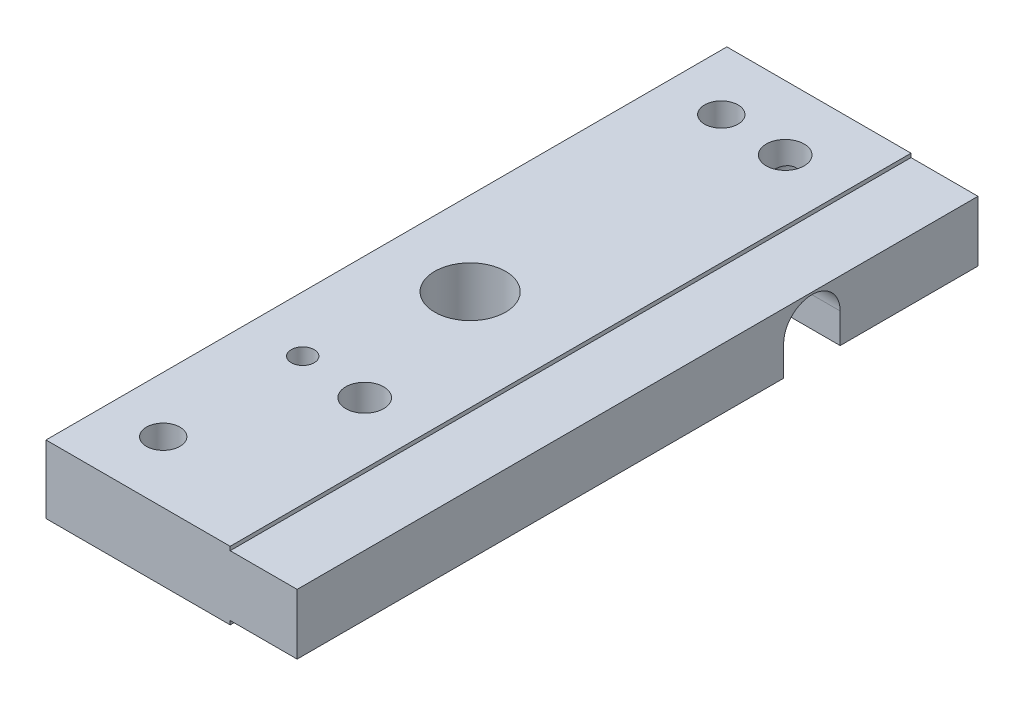
from build123d import *

# Parameters (mm, degrees)
SKETCH1_W                                        = 61
SKETCH1_H                                        = 6.1
BOSS_EXTRUDE1_DEPTH                              = 22.5
SKETCH2_OUTSIDE_W                                = 76.06
SKETCH2_OUTSIDE_H                                = 21.16
SKETCH2_OUTSIDE_W_2                              = 61
SKETCH2_OUTSIDE_H_2                              = 5.41284
CUT_EXTRUDE1_DEPTH                               = 6
CUT_EXTRUDE3_DEPTH                               = 23.5
SKETCH6_R                                        = 3.175
CUT_EXTRUDE4_DEPTH                               = 7.1
SKETCH7_R                                        = 1.5
CUT_EXTRUDE5_DEPTH                               = 7.1
M2_5X0_45_TAPPED_HOLE1_D                         = 2.05
M2_5X0_45_TAPPED_HOLE2_D                         = 2.05
M2_5X0_45_TAPPED_HOLE2_DEPTH                     = 7.3
M2_5X0_45_TAPPED_HOLE2_TIP                       = 0.615882135
CBORE_FOR_M3_PAN_HEAD_MACHINE_SCREW1_D           = 3.4
CBORE_FOR_M3_PAN_HEAD_MACHINE_SCREW1_CBORE_D     = 6.5
CBORE_FOR_M3_PAN_HEAD_MACHINE_SCREW1_CBORE_DEPTH = 2.2


with BuildPart() as part:
    # Sketch1 → Boss-Extrude1 (new body)
    with BuildSketch(Plane(origin=(0, 0, 0), x_dir=(0, 0, -1), z_dir=(1, 0, 0))):
        with Locations((30.5, 0)):
            Rectangle(SKETCH1_W, SKETCH1_H)
    extrude(amount=BOSS_EXTRUDE1_DEPTH)

    # Sketch2 outside → Cut-Extrude1 (cut)
    with BuildSketch(Plane(origin=(22.5, 0, 0), x_dir=(0, 0, -1), z_dir=(1, 0, 0))):
        with Locations((30.5, 0)):
            Rectangle(SKETCH2_OUTSIDE_W, SKETCH2_OUTSIDE_H)
        with Locations((30.5, 0)):
            Rectangle(SKETCH2_OUTSIDE_W_2, SKETCH2_OUTSIDE_H_2, mode=Mode.SUBTRACT)
    extrude(amount=-CUT_EXTRUDE1_DEPTH, mode=Mode.SUBTRACT)

    # Sketch5 → Cut-Extrude3 (cut, through all)
    with BuildSketch(Plane.ZY):
        with BuildLine():
            Line((-43.5866, -0.01898), (-43.5866, -3.05))
            Line((-43.5866, -3.05), (-48.6514, -3.05))
            Line((-48.6514, -3.05), (-48.6514, -0.01898))
            ThreePointArc((-48.6514, -0.01898), (-46.119, 2.51342), (-43.5866, -0.01898))
        make_face()
    extrude(amount=-CUT_EXTRUDE3_DEPTH, mode=Mode.SUBTRACT)

    # Sketch6 → Cut-Extrude4 (cut, through all)
    with BuildSketch(Plane(origin=(0, 3.05, 0), x_dir=(1, 0, 0), z_dir=(0, 1, 0))):
        with Locations(Location((7.5, 30.5, 0), (0, 0, 270))):  # turned: the seam where the file's is
            Circle(SKETCH6_R)
    extrude(amount=-CUT_EXTRUDE4_DEPTH, mode=Mode.SUBTRACT)

    # Sketch7 → Cut-Extrude5 (cut, through all)
    with BuildSketch(Plane(origin=(0, 3.05, 0), x_dir=(1, 0, 0), z_dir=(0, 1, 0))):
        with Locations(Location((5, 55.5, 0), (0, 0, 270))):  # turned: the seam where the file's is
            Circle(SKETCH7_R)
        with Locations(Location((5, 5.5, 0), (0, 0, 270))):  # turned: the seam where the file's is
            Circle(SKETCH7_R)
    extrude(amount=-CUT_EXTRUDE5_DEPTH, mode=Mode.SUBTRACT)

    # M2.5x0.45 Tapped Hole1 (through all)
    with Locations(Plane(origin=(0, -3.05, 0), x_dir=(-1, 0, 0), z_dir=(0, -1, 0))):
        with Locations((-5, 18)):
            Hole(M2_5X0_45_TAPPED_HOLE1_D / 2)

    # M2.5x0.45 Tapped Hole2
    with Locations(Plane(origin=(0, 0, -61), x_dir=(-1, 0, 0), z_dir=(0, 0, -1))):
        with Locations((-10, 0)):
            Hole(M2_5X0_45_TAPPED_HOLE2_D / 2, depth=M2_5X0_45_TAPPED_HOLE2_DEPTH)
            with Locations((0, 0, -(M2_5X0_45_TAPPED_HOLE2_DEPTH + M2_5X0_45_TAPPED_HOLE2_TIP / 2))):  # 118° drill point
                Cone(0, M2_5X0_45_TAPPED_HOLE2_D / 2, M2_5X0_45_TAPPED_HOLE2_TIP, mode=Mode.SUBTRACT)

    # CBORE for M3 Pan Head Machine Screw1 (through all)
    with Locations(Plane(origin=(0, -3.05, 0), x_dir=(-1, 0, 0), z_dir=(0, -1, 0))):
        with Locations((-11, 55.228), (-11, 17.553)):
            CounterBoreHole(CBORE_FOR_M3_PAN_HEAD_MACHINE_SCREW1_D / 2, CBORE_FOR_M3_PAN_HEAD_MACHINE_SCREW1_CBORE_D / 2, CBORE_FOR_M3_PAN_HEAD_MACHINE_SCREW1_CBORE_DEPTH)


solid = part.part
